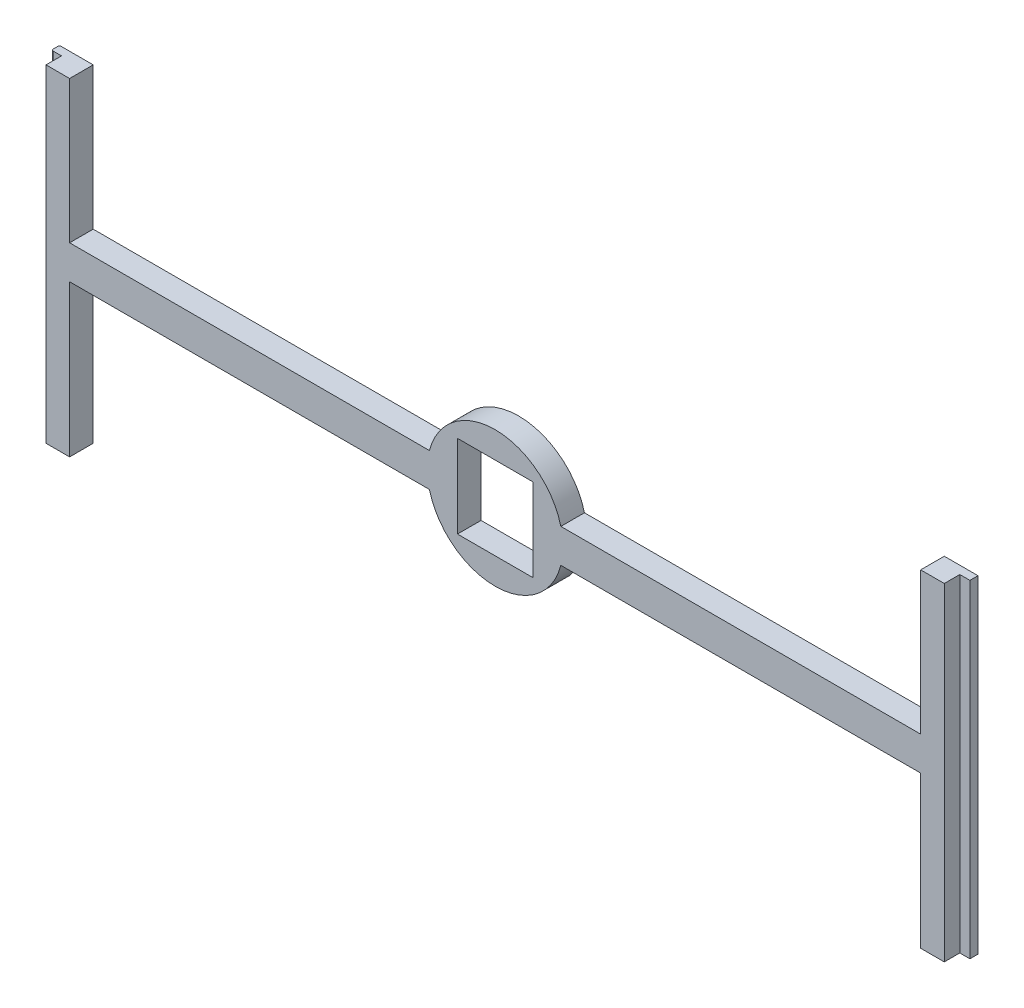
from build123d import *

# Parameters (mm, degrees)
SKETCH1_R           = 2.54
BOSS_EXTRUDE1_DEPTH = 3.5
SKETCH2_W           = 1.5
SKETCH2_H           = 2.3
CUT_EXTRUDE1_DEPTH  = 51
SKETCH3_W           = 11.176
SKETCH3_H           = 12.2936
CUT_EXTRUDE2_DEPTH  = 3.81
SKETCH4_W           = 136.2
SKETCH4_H           = 1.4
CUT_EXTRUDE3_DEPTH  = 4.5
FILLET1_R           = 0.3


with BuildPart() as part:
    # Sketch1 → Boss-Extrude1 (new body)
    with BuildSketch(Plane.XY):
        with BuildLine():
            Line((-63.1, 2.5), (-9.742761957, 2.5))
            ThreePointArc((-9.742761957, 2.5), (0, 10.0584), (9.742761957, 2.5))
            Line((9.742761957, 2.5), (63.1, 2.5))
            Line((63.1, 2.5), (63.1, 25))
            Line((63.1, 25), (68.1, 25))
            Line((68.1, 25), (68.1, -25))
            Line((68.1, -25), (63.1, -25))
            Line((63.1, -25), (63.1, -2.5))
            Line((63.1, -2.5), (9.742761957, -2.5))
            ThreePointArc((9.742761957, -2.5), (0, -10.0584), (-9.742761957, -2.5))
            Line((-9.742761957, -2.5), (-63.1, -2.5))
            Line((-63.1, -2.5), (-63.1, -25))
            Line((-63.1, -25), (-68.1, -25))
            Line((-68.1, -25), (-68.1, 25))
            Line((-68.1, 25), (-63.1, 25))
            Line((-63.1, 25), (-63.1, 2.5))
        make_face()
        Circle(SKETCH1_R, mode=Mode.SUBTRACT)
    extrude(amount=BOSS_EXTRUDE1_DEPTH)

    # Sketch2 → Cut-Extrude1 (cut, through all)
    with BuildSketch(Plane.XZ.offset(25)):
        with Locations((67.35, 2.35)):
            Rectangle(SKETCH2_W, SKETCH2_H)
        with Locations((-67.35, 2.35)):
            Rectangle(SKETCH2_W, SKETCH2_H)
    extrude(amount=-CUT_EXTRUDE1_DEPTH, mode=Mode.SUBTRACT)

    # Sketch3 → Cut-Extrude2 (cut)
    with BuildSketch(Plane.XY.offset(3.5)):
        Rectangle(SKETCH3_W, SKETCH3_H)
    extrude(amount=-CUT_EXTRUDE2_DEPTH, mode=Mode.SUBTRACT)

    # Sketch4 → Cut-Extrude3 (cut, through all)
    with BuildSketch(Plane.XY.offset(3.5)):
        with Locations((0, 24.3)):
            Rectangle(SKETCH4_W, SKETCH4_H)
    extrude(amount=-CUT_EXTRUDE3_DEPTH, mode=Mode.SUBTRACT)

    # Fillet1
    fillet1_edges = [part.edges().sort_by_distance(p)[0] for p in [
        (-68.1, -0.7, 1.2),
        (-68.1, -0.7, 0),
    ]]
    fillet(fillet1_edges, radius=FILLET1_R)


solid = part.part
